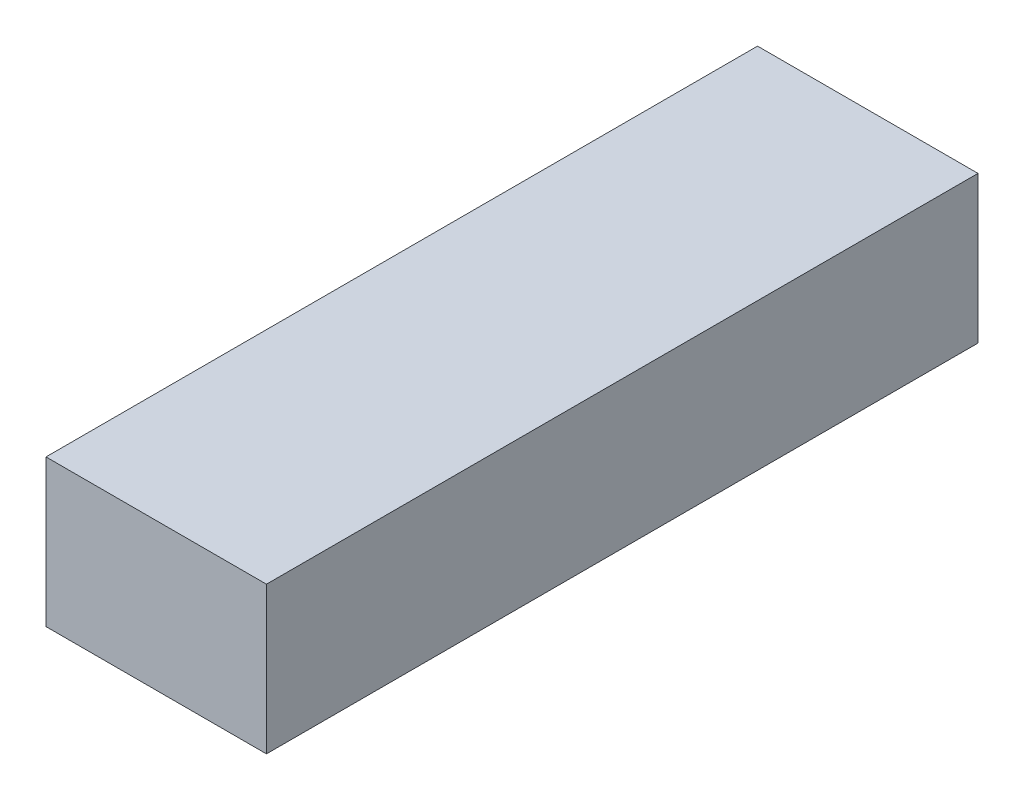
from build123d import *

# Parameters (mm, degrees)
SKETCH1_W           = 48.006
SKETCH1_H           = 32.004
BOSS_EXTRUDE1_DEPTH = 154.94


with BuildPart() as part:
    # Sketch1 → Boss-Extrude1 (new body)
    with BuildSketch(Plane.XY):
        Rectangle(SKETCH1_W, SKETCH1_H)
    extrude(amount=BOSS_EXTRUDE1_DEPTH)


solid = part.part
